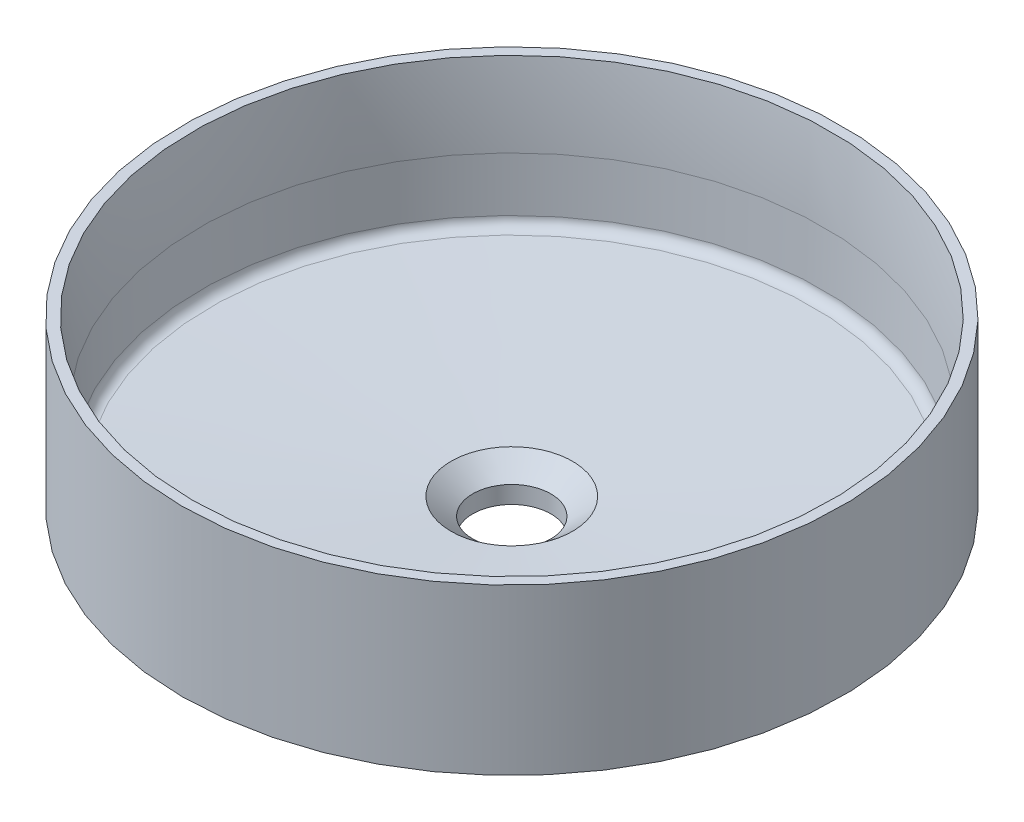
from build123d import *

# Parameters (mm, degrees)
SKETCH_1_R      = 190
EXTRUDE_1_DEPTH = 95
SKETCH_2_R      = 167.5
EXTRUDE_2_DEPTH = 15
SKETCH_4_R      = 167.5
FILLET_1_R      = 5
FILLET_2_R      = 6
FILLET_3_R      = 10


with BuildPart() as part:
    # 草图1 → 凸台-拉伸1 (new body)
    with BuildSketch(Plane(origin=(0, 0, 0), x_dir=(1, 0, 0), z_dir=(0, 1, 0))):
        with Locations(Location((0, 0, 0), (0, 0, 270))):
            Circle(SKETCH_1_R)
    extrude(amount=-EXTRUDE_1_DEPTH)

    # 草图2 → 凸台-拉伸2 (add)
    with BuildSketch(Plane.XZ.offset(95)):
        with Locations(Location((0, 0, 0), (0, 0, 90))):
            Circle(SKETCH_2_R)
    extrude(amount=EXTRUDE_2_DEPTH)

    # 草图4 → section 1 of loft_1
    with BuildSketch(Plane(origin=(0, -97, 0), x_dir=(-1, 0, 0), z_dir=(0, -1, 0)), mode=Mode.PRIVATE) as loft_1_s1:
        Circle(SKETCH_4_R)
    # loft up to a face of the part (loft_1)
    loft([Face(Wire([part.edges().sort_by_distance((-138.50403921, -95, -130.063950126))[0]])), loft_1_s1.sketch])

    # 圆角1
    fillet_1_edges = [part.edges().sort_by_distance(p)[0] for p in [
        (0, -97, -167.5),
    ]]
    fillet(fillet_1_edges, radius=FILLET_1_R)

    # 草图3 → 切除-旋转1 (revolve, cut)
    with BuildSketch(Plane.XY, mode=Mode.PRIVATE) as cut_revolve_1_sk:
        with BuildLine():
            Line((-179, -82), (-35, -90))
            Line((-35, -90), (-22.5, -100))
            Line((-22.5, -100), (-22.5, -110))
            Line((-22.5, -110), (0, -110))
            Line((0, -110), (0, 0))
            Line((0, 0), (-184, 0))
            ThreePointArc((-184, 0), (-181.595265599, -22.984806931), (-180.255185832, -46.056180609))
            Line((-180.255185832, -46.056180609), (-179, -82))
        make_face()
        Polygon((-157.5, -110), (-156.5, -93.26542021), (-55, -98.904309099), (-55, -110), align=None)
    revolve(cut_revolve_1_sk.sketch.rotate(Axis((0, 0, 0), (0, -1, 0)), 270), axis=Axis((0, 0, 0), (0, -1, 0)), mode=Mode.SUBTRACT)

    # 圆角2
    fillet_2_edges = [part.edges().sort_by_distance(p)[0] for p in [
        (0, -82, -179),
    ]]
    fillet(fillet_2_edges, radius=FILLET_2_R)

    # 圆角3
    fillet_3_edges = [part.edges().sort_by_distance(p)[0] for p in [
        (0, -98.904309099, -55),
        (0, -93.26542021, -156.5),
    ]]
    fillet(fillet_3_edges, radius=FILLET_3_R)


solid = part.part
